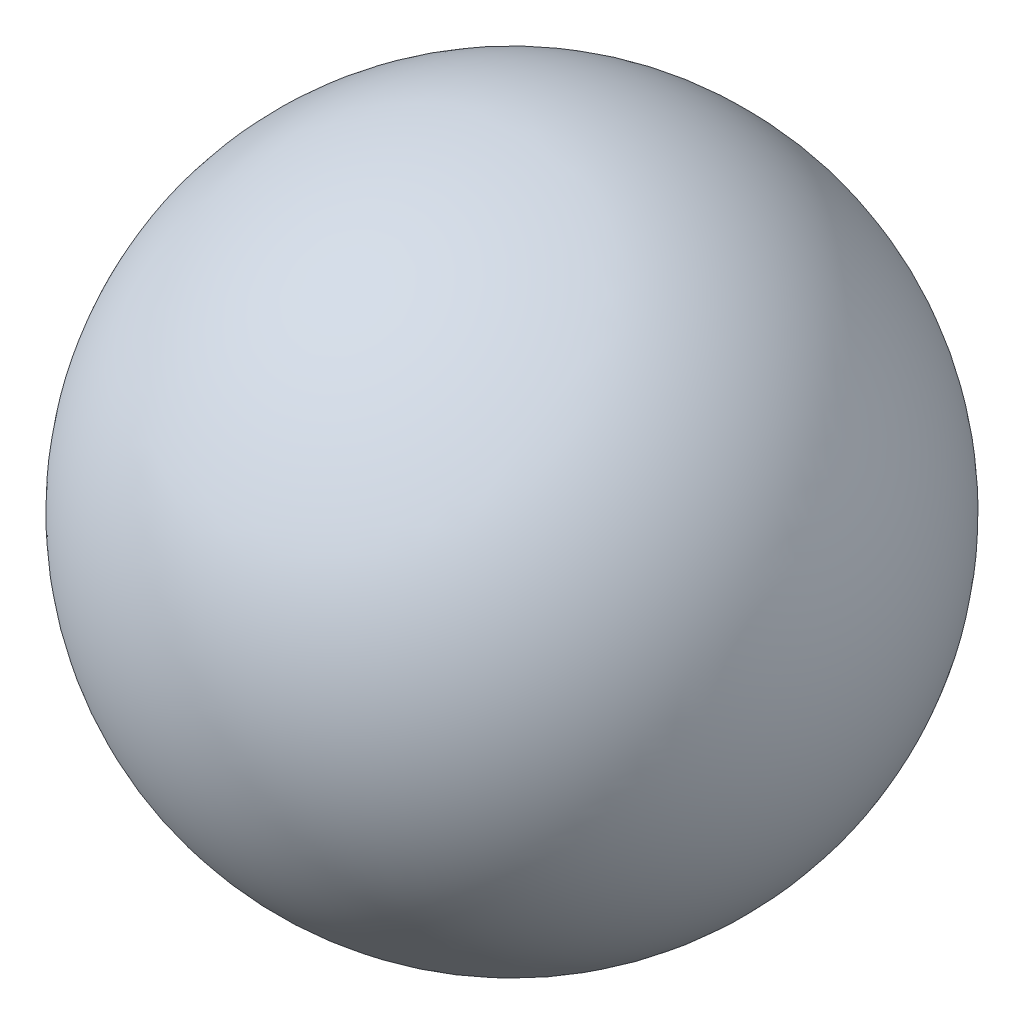
from build123d import *


with BuildPart() as part:
    # Sketch1 → Revolve1 (revolve)
    with BuildSketch(Plane.XY):
        with BuildLine():
            Line((-2.25, 0), (2.25, 0))
            ThreePointArc((2.25, 0), (0, -2.25), (-2.25, 0))
        make_face()
    revolve(axis=Axis((-2.25, 0, 0), (1, 0, 0)))


solid = part.part
